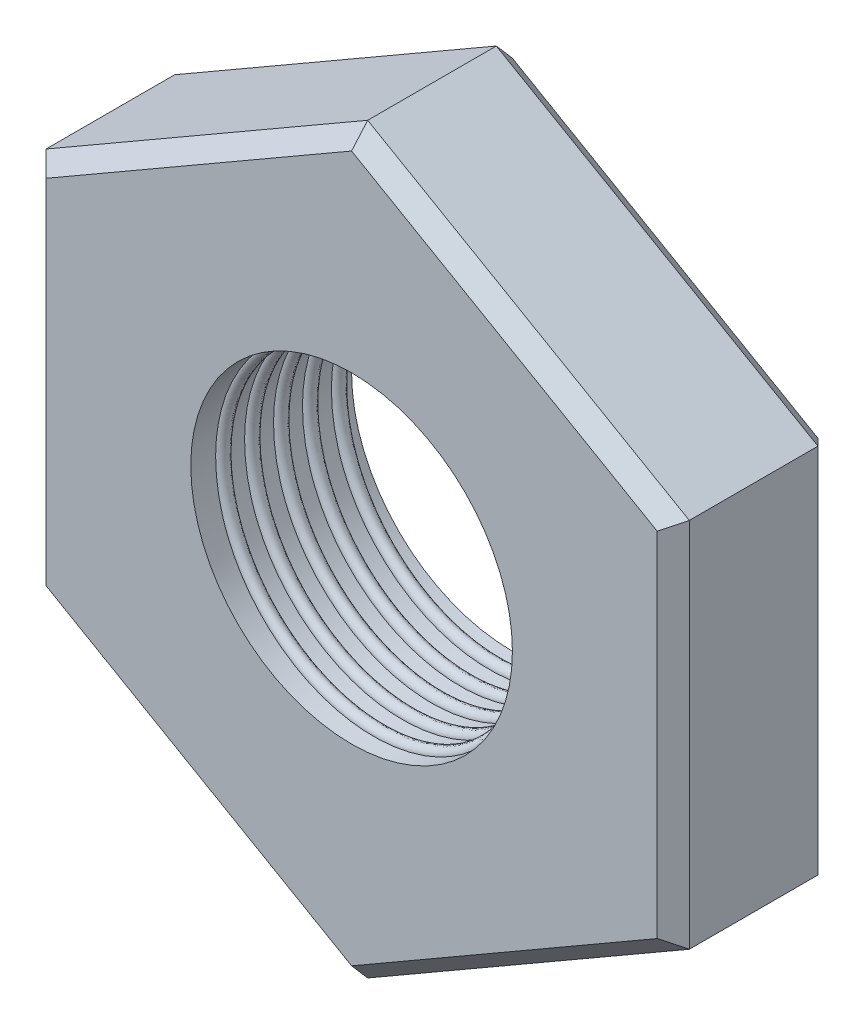
from build123d import *

# Parameters (mm, degrees)
BOSS_EXTRUDE1_DEPTH     = 5
SKETCH2_R               = 5
CUT_EXTRUDE1_DEPTH      = 1
CUT_EXTRUDE1_DEPTH_BACK = 6
SWEEP1_PITCH            = 0.9
SWEEP1_HEIGHT           = 4.5
SWEEP1_RADIUS           = 5
SWEEP1_START_ANGLE      = 90
CHAMFER1_SIZE           = 0.5


with BuildPart() as part:
    # Sketch1 → Boss-Extrude1 (new body)
    with BuildSketch(Plane.XY):
        Polygon((0, 11.547005384), (-10, 5.773502692), (-10, -5.773502692), (0, -11.547005384), (10, -5.773502692), (10, 5.773502692), align=None)
    extrude(amount=BOSS_EXTRUDE1_DEPTH)

    # Sketch2 → Cut-Extrude1 (cut, two sides)
    with BuildSketch(Plane.XY.offset(5)) as cut_extrude1_sk:
        Circle(SKETCH2_R)
    extrude(amount=CUT_EXTRUDE1_DEPTH, mode=Mode.SUBTRACT)
    extrude(cut_extrude1_sk.sketch, amount=-CUT_EXTRUDE1_DEPTH_BACK, mode=Mode.SUBTRACT)

    # Sweep1: sweep along a helix
    with BuildLine() as sweep1_path:
        add(Helix(SWEEP1_PITCH, SWEEP1_HEIGHT, SWEEP1_RADIUS, center=(0, 0, 5), direction=(0, 0, -1), mode=Mode.PRIVATE).rotate(Axis((0, 0, 5), (0, 0, -1)), SWEEP1_START_ANGLE))
    # Sketch4 → Sweep1 (sweep)
    with BuildSketch(Plane(origin=(0, 0, 0), x_dir=(0, 0, -1), z_dir=(1, 0, 0))):
        with BuildLine():
            Line((0, 5), (-0.4, 5))
            ThreePointArc((-0.4, 5), (-0.2, 4.8), (0, 5))
        make_face()
    sweep(path=sweep1_path.line, is_frenet=True)

    # Chamfer1
    chamfer1_edges = [part.edges().sort_by_distance(p)[0] for p in [
        (-10, 0, 5),
        (-5, -8.660254038, 5),
        (5, -8.660254038, 5),
        (10, 0, 5),
        (5, 8.660254038, 5),
        (10, 0, 0),
        (5, -8.660254038, 0),
        (-5, -8.660254038, 0),
        (-5, 8.660254038, 5),
        (-10, 0, 0),
        (-5, 8.660254038, 0),
        (5, 8.660254038, 0),
    ]]
    chamfer(chamfer1_edges, length=CHAMFER1_SIZE)


solid = part.part
